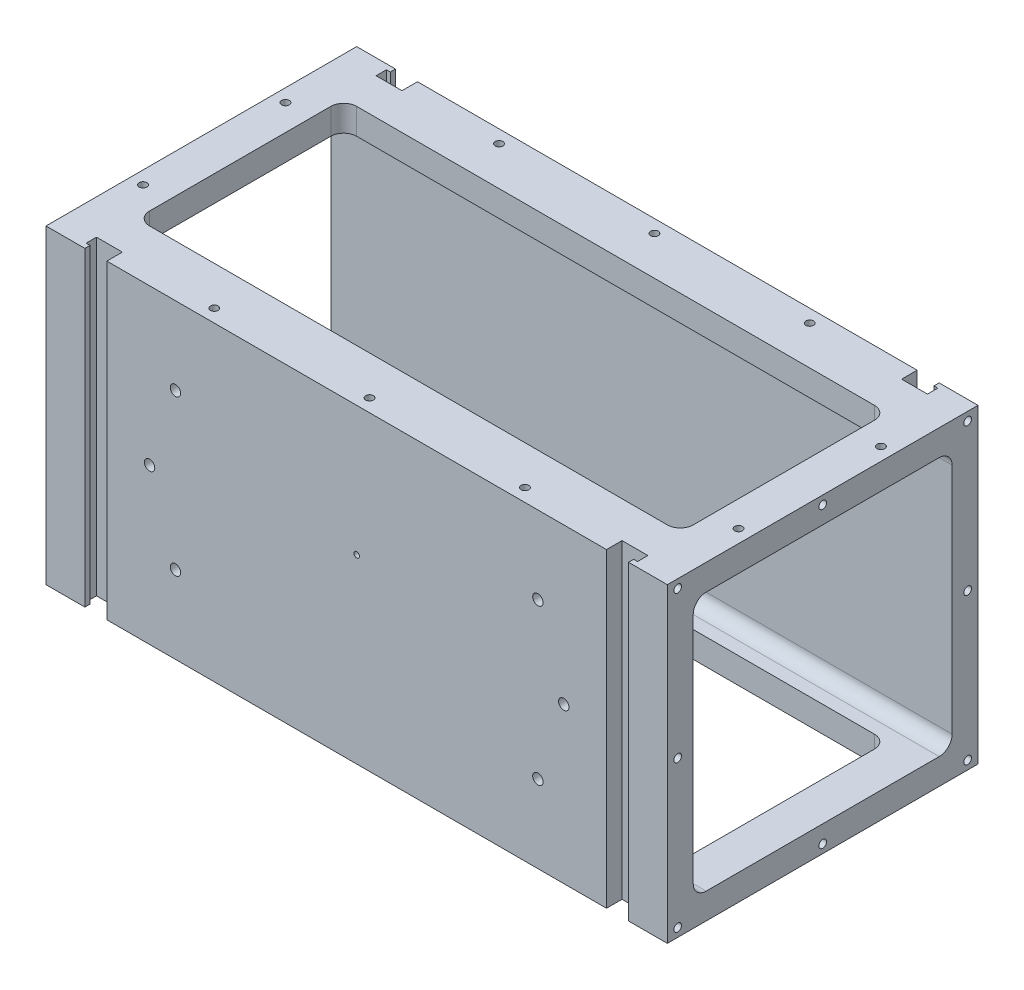
from build123d import *

# Parameters (mm, degrees)
SKETCH1_W                       = 304.8
SKETCH1_H                       = 152.4
BOSS_EXTRUDE1_DEPTH             = 152.4
CUT_EXTRUDE1_DEPTH              = 153.4
SKETCH6_W                       = 127
SKETCH6_H                       = 127
CUT_EXTRUDE5_DEPTH              = 305.8
CUT_EXTRUDE6_REACH              = 154.4
SKETCH7_W                       = 266.7
SKETCH7_H                       = 88.9
SKETCH8_W                       = 266.7
SKETCH8_H                       = 101.6
CUT_EXTRUDE7_DEPTH              = 153.4
F_1_4_20_TAPPED_HOLE2_D         = 5.1054
F_1_4_20_TAPPED_HOLE2_DEPTH     = 8.89
F_1_4_20_TAPPED_HOLE2_TIP       = 1.533816902
F_6_32_TAPPED_HOLE1_D           = 2.7051
F_6_32_TAPPED_HOLE1_DEPTH       = 9.38784
F_6_32_TAPPED_HOLE1_TIP         = 0.81269403
F_1_4_20_TAPPED_HOLE1_D         = 5.1054
F_1_4_20_TAPPED_HOLE1_DEPTH     = 8.89
F_1_4_20_TAPPED_HOLE1_TIP       = 1.533816902
F_10_24_TAPPED_HOLE1_AT_2_COUNT = 2
F_10_24_TAPPED_HOLE1_AT_2_PITCH = 78.094674114
F_10_24_TAPPED_HOLE1_AT_3_COUNT = 2
F_10_24_TAPPED_HOLE1_AT_3_PITCH = 292.1
F_10_24_TAPPED_HOLE1_AT_4_COUNT = 2
F_10_24_TAPPED_HOLE1_AT_4_PITCH = 224.977372473
F_10_24_TAPPED_HOLE1_AT_5_COUNT = 2
F_10_24_TAPPED_HOLE1_AT_5_PITCH = 300.335533196
F_10_24_TAPPED_HOLE1_AT_6_COUNT = 2
F_10_24_TAPPED_HOLE1_AT_6_PITCH = 245.708899157
F_10_24_TAPPED_HOLE1_AT_7_COUNT = 2
F_10_24_TAPPED_HOLE1_AT_7_PITCH = 69.85
F_10_24_TAPPED_HOLE1_AT_8_COUNT = 2
F_10_24_TAPPED_HOLE1_AT_8_PITCH = 125.923878296
F_10_24_TAPPED_HOLE2_AT_2_COUNT = 2
F_10_24_TAPPED_HOLE2_AT_2_PITCH = 139.7
F_10_24_TAPPED_HOLE5_AT_2_COUNT = 2
F_10_24_TAPPED_HOLE5_AT_2_PITCH = 144.018
F_10_24_TAPPED_HOLE5_AT_3_COUNT = 2
F_10_24_TAPPED_HOLE5_AT_3_PITCH = 202.41887739
F_10_24_TAPPED_HOLE5_AT_4_COUNT = 2
F_10_24_TAPPED_HOLE5_AT_4_PITCH = 160.621414276
F_10_24_TAPPED_HOLE5_AT_5_COUNT = 2
F_10_24_TAPPED_HOLE5_AT_5_PITCH = 142.24
F_10_24_TAPPED_HOLE5_AT_6_COUNT = 2
F_10_24_TAPPED_HOLE5_AT_6_PITCH = 159.428710341
F_10_24_TAPPED_HOLE5_AT_7_COUNT = 2
F_10_24_TAPPED_HOLE5_AT_7_PITCH = 71.086625417
F_10_24_TAPPED_HOLE5_AT_8_COUNT = 2
F_10_24_TAPPED_HOLE5_AT_8_PITCH = 72.009
F_6_32_TAPPED_HOLE2_D           = 2.7051
F_6_32_TAPPED_HOLE2_DEPTH       = 9.38784
F_6_32_TAPPED_HOLE2_TIP         = 0.81269403
FILLET1_R                       = 6.35
FILLET2_R                       = 6.35
MIRROR2_COPY_1_DEPTH            = 153.4
F_1_4_20_TAPPED_HOLE3_D         = 5.1054
F_1_4_20_TAPPED_HOLE3_DEPTH     = 7.8105
F_1_4_20_TAPPED_HOLE3_TIP       = 1.533816902


with BuildPart() as part:
    # Sketch1 → Boss-Extrude1 (new body)
    with BuildSketch(Plane.XY.offset(76.2)):
        Rectangle(SKETCH1_W, SKETCH1_H)
    extrude(amount=-BOSS_EXTRUDE1_DEPTH)

    # Sketch2 → Cut-Extrude1 (cut, through all)
    with BuildSketch(Plane(origin=(0, 76.2, 0), x_dir=(-1, 0, 0), z_dir=(0, 1, 0))):
        Polygon((133.35, -76.2), (133.35, -73.66), (135.255, -73.66), (135.255, -68.58), (122.555, -68.58), (122.555, -76.2), align=None)
    cut_extrude1 = extrude(amount=-CUT_EXTRUDE1_DEPTH, mode=Mode.SUBTRACT)

    # Sketch6 → Cut-Extrude5 (cut, through all)
    with BuildSketch(Plane.ZY.offset(152.4)):
        Rectangle(SKETCH6_W, SKETCH6_H)
    extrude(amount=-CUT_EXTRUDE5_DEPTH, mode=Mode.SUBTRACT)

    # Sketch7 → Cut-Extrude6 (cut, up to next)
    with BuildSketch(Plane.XZ.offset(76.2), mode=Mode.PRIVATE) as cut_extrude6_sk1:
        Rectangle(SKETCH7_W, SKETCH7_H)
    cut_extrude6_tool1 = extrude(cut_extrude6_sk1.sketch, amount=-CUT_EXTRUDE6_REACH, mode=Mode.PRIVATE) & part.part
    add(cut_extrude6_tool1.solids().sort_by_distance((0, -76.2, 0))[0], mode=Mode.SUBTRACT)

    # Sketch8 → Cut-Extrude7 (cut, through all)
    with BuildSketch(Plane(origin=(0, 76.2, 0), x_dir=(-1, 0, 0), z_dir=(0, 1, 0))):
        Rectangle(SKETCH8_W, SKETCH8_H)
    extrude(amount=-CUT_EXTRUDE7_DEPTH, mode=Mode.SUBTRACT)

    # 1/4-20 Tapped Hole2
    with Locations(Plane(origin=(0, 0, -76.2), x_dir=(-1, 0, 0), z_dir=(0, 0, -1))):
        with Locations((88.9, 38.1), (-88.9, 38.1), (88.9, -38.1), (-88.9, -38.1)):
            Hole(F_1_4_20_TAPPED_HOLE2_D / 2, depth=F_1_4_20_TAPPED_HOLE2_DEPTH)
            with Locations((0, 0, -(F_1_4_20_TAPPED_HOLE2_DEPTH + F_1_4_20_TAPPED_HOLE2_TIP / 2))):  # 118° drill point
                Cone(0, F_1_4_20_TAPPED_HOLE2_D / 2, F_1_4_20_TAPPED_HOLE2_TIP, mode=Mode.SUBTRACT)

    # #6-32 Tapped Hole1
    with Locations(Plane(origin=(0, 0, -76.2), x_dir=(-1, 0, 0), z_dir=(0, 0, -1))):
        with Locations((0, 12.7)):
            Hole(F_6_32_TAPPED_HOLE1_D / 2, depth=F_6_32_TAPPED_HOLE1_DEPTH)
            with Locations((0, 0, -(F_6_32_TAPPED_HOLE1_DEPTH + F_6_32_TAPPED_HOLE1_TIP / 2))):  # 118° drill point
                Cone(0, F_6_32_TAPPED_HOLE1_D / 2, F_6_32_TAPPED_HOLE1_TIP, mode=Mode.SUBTRACT)

    # 1/4-20 Tapped Hole1
    with Locations(Plane.XY.offset(76.2)):
        with Locations((-88.9, -38.1), (88.9, -38.1), (88.9, 38.1), (-88.9, 38.1)):
            Hole(F_1_4_20_TAPPED_HOLE1_D / 2, depth=F_1_4_20_TAPPED_HOLE1_DEPTH)
            with Locations((0, 0, -(F_1_4_20_TAPPED_HOLE1_DEPTH + F_1_4_20_TAPPED_HOLE1_TIP / 2))):  # 118° drill point
                Cone(0, F_1_4_20_TAPPED_HOLE1_D / 2, F_1_4_20_TAPPED_HOLE1_TIP, mode=Mode.SUBTRACT)

    # Sketch15 → #10-24 Tapped Hole1 (revolve, cut)
    with BuildSketch(Plane(origin=(-146.05, 76.2, 34.925), x_dir=(0, 0, 1), z_dir=(1, 0, 0))):
        Polygon((0, 0), (0, 8.890364014), (1.89865, 7.74954), (1.89865, 0), align=None)
    f_10_24_tapped_hole1 = revolve(axis=Axis((-146.05, 82.55, 34.925), (0, -1, 0)), mode=Mode.SUBTRACT)

    # #10-24 Tapped Hole1 at 2: #10-24 Tapped Hole1 ×2
    with Locations(*[Vector(0.894427191, 0, 0.447213595) * (i * F_10_24_TAPPED_HOLE1_AT_2_PITCH) for i in range(1, F_10_24_TAPPED_HOLE1_AT_2_COUNT)]):
        add(f_10_24_tapped_hole1, mode=Mode.SUBTRACT)

    # #10-24 Tapped Hole1 at 3: #10-24 Tapped Hole1 ×2
    with Locations(*[(i * F_10_24_TAPPED_HOLE1_AT_3_PITCH, 0, 0) for i in range(1, F_10_24_TAPPED_HOLE1_AT_3_COUNT)]):
        add(f_10_24_tapped_hole1, mode=Mode.SUBTRACT)

    # #10-24 Tapped Hole1 at 4: #10-24 Tapped Hole1 ×2
    with Locations(*[Vector(0.987877125, 0, 0.155237834) * (i * F_10_24_TAPPED_HOLE1_AT_4_PITCH) for i in range(1, F_10_24_TAPPED_HOLE1_AT_4_COUNT)]):
        add(f_10_24_tapped_hole1, mode=Mode.SUBTRACT)

    # #10-24 Tapped Hole1 at 5: #10-24 Tapped Hole1 ×2
    with Locations(*[Vector(0.972578892, 0, -0.232573213) * (i * F_10_24_TAPPED_HOLE1_AT_5_PITCH) for i in range(1, F_10_24_TAPPED_HOLE1_AT_5_COUNT)]):
        add(f_10_24_tapped_hole1, mode=Mode.SUBTRACT)

    # #10-24 Tapped Hole1 at 6: #10-24 Tapped Hole1 ×2
    with Locations(*[Vector(0.904525643, 0, -0.426419232) * (i * F_10_24_TAPPED_HOLE1_AT_6_PITCH) for i in range(1, F_10_24_TAPPED_HOLE1_AT_6_COUNT)]):
        add(f_10_24_tapped_hole1, mode=Mode.SUBTRACT)

    # #10-24 Tapped Hole1 at 7: #10-24 Tapped Hole1 ×2
    with Locations(*[(0, 0, -i * F_10_24_TAPPED_HOLE1_AT_7_PITCH) for i in range(1, F_10_24_TAPPED_HOLE1_AT_7_COUNT)]):
        add(f_10_24_tapped_hole1, mode=Mode.SUBTRACT)

    # #10-24 Tapped Hole1 at 8: #10-24 Tapped Hole1 ×2
    with Locations(*[Vector(0.554700196, 0, -0.832050294) * (i * F_10_24_TAPPED_HOLE1_AT_8_PITCH) for i in range(1, F_10_24_TAPPED_HOLE1_AT_8_COUNT)]):
        add(f_10_24_tapped_hole1, mode=Mode.SUBTRACT)

    # Sketch17 → #10-24 Tapped Hole2 (revolve, cut)
    with BuildSketch(Plane(origin=(0, 76.2, 69.85), x_dir=(0, 0, 1), z_dir=(1, 0, 0))):
        Polygon((0, 0), (0, 13.970364014), (1.89865, 12.82954), (1.89865, 0), align=None)
    f_10_24_tapped_hole2 = revolve(axis=Axis((0, 82.55, 69.85), (0, -1, 0)), mode=Mode.SUBTRACT)

    # #10-24 Tapped Hole2 at 2: #10-24 Tapped Hole2 ×2
    with Locations(*[(0, 0, -i * F_10_24_TAPPED_HOLE2_AT_2_PITCH) for i in range(1, F_10_24_TAPPED_HOLE2_AT_2_COUNT)]):
        add(f_10_24_tapped_hole2, mode=Mode.SUBTRACT)

    # Sketch25 → #10-24 Tapped Hole5 (revolve, cut)
    with BuildSketch(Plane(origin=(152.4, 72.009, -71.12), x_dir=(0, 0, -1), z_dir=(0, 1, 0))):
        Polygon((0, 0), (0, 11.430364014), (1.89865, 10.28954), (1.89865, 0), align=None)
    f_10_24_tapped_hole5 = revolve(axis=Axis((158.75, 72.009, -71.12), (-1, 0, 0)), mode=Mode.SUBTRACT)

    # #10-24 Tapped Hole5 at 2: #10-24 Tapped Hole5 ×2
    with Locations(*[(0, -i * F_10_24_TAPPED_HOLE5_AT_2_PITCH, 0) for i in range(1, F_10_24_TAPPED_HOLE5_AT_2_COUNT)]):
        add(f_10_24_tapped_hole5, mode=Mode.SUBTRACT)

    # #10-24 Tapped Hole5 at 3: #10-24 Tapped Hole5 ×2
    with Locations(*[Vector(0, -0.711485025, 0.702701259) * (i * F_10_24_TAPPED_HOLE5_AT_3_PITCH) for i in range(1, F_10_24_TAPPED_HOLE5_AT_3_COUNT)]):
        add(f_10_24_tapped_hole5, mode=Mode.SUBTRACT)

    # #10-24 Tapped Hole5 at 4: #10-24 Tapped Hole5 ×2
    with Locations(*[Vector(0, -0.896630133, 0.442780312) * (i * F_10_24_TAPPED_HOLE5_AT_4_PITCH) for i in range(1, F_10_24_TAPPED_HOLE5_AT_4_COUNT)]):
        add(f_10_24_tapped_hole5, mode=Mode.SUBTRACT)

    # #10-24 Tapped Hole5 at 5: #10-24 Tapped Hole5 ×2
    with Locations(*[(0, 0, i * F_10_24_TAPPED_HOLE5_AT_5_PITCH) for i in range(1, F_10_24_TAPPED_HOLE5_AT_5_COUNT)]):
        add(f_10_24_tapped_hole5, mode=Mode.SUBTRACT)

    # #10-24 Tapped Hole5 at 6: #10-24 Tapped Hole5 ×2
    with Locations(*[Vector(0, -0.451668961, 0.892185603) * (i * F_10_24_TAPPED_HOLE5_AT_6_PITCH) for i in range(1, F_10_24_TAPPED_HOLE5_AT_6_COUNT)]):
        add(f_10_24_tapped_hole5, mode=Mode.SUBTRACT)

    # #10-24 Tapped Hole5 at 7: #10-24 Tapped Hole5 ×2
    with Locations(*[(0, 0, i * F_10_24_TAPPED_HOLE5_AT_7_PITCH) for i in range(1, F_10_24_TAPPED_HOLE5_AT_7_COUNT)]):
        add(f_10_24_tapped_hole5, mode=Mode.SUBTRACT)

    # #10-24 Tapped Hole5 at 8: #10-24 Tapped Hole5 ×2
    with Locations(*[(0, -i * F_10_24_TAPPED_HOLE5_AT_8_PITCH, 0) for i in range(1, F_10_24_TAPPED_HOLE5_AT_8_COUNT)]):
        add(f_10_24_tapped_hole5, mode=Mode.SUBTRACT)

    # #6-32 Tapped Hole2
    with Locations(Plane.XY.offset(76.2)):
        with Locations((0, 12.7)):
            Hole(F_6_32_TAPPED_HOLE2_D / 2, depth=F_6_32_TAPPED_HOLE2_DEPTH)
            with Locations((0, 0, -(F_6_32_TAPPED_HOLE2_DEPTH + F_6_32_TAPPED_HOLE2_TIP / 2))):  # 118° drill point
                Cone(0, F_6_32_TAPPED_HOLE2_D / 2, F_6_32_TAPPED_HOLE2_TIP, mode=Mode.SUBTRACT)

    # Fillet1
    fillet1_edges = [part.edges().sort_by_distance(p)[0] for p in [
        (133.35, -69.85, 50.8),
        (133.35, 69.85, 50.8),
        (-133.35, -69.85, -50.8),
        (-133.35, 69.85, -50.8),
        (-133.35, -69.85, 50.8),
        (-133.35, 69.85, 50.8),
        (133.35, -69.85, -50.8),
        (133.35, 69.85, -50.8),
    ]]
    fillet(fillet1_edges, radius=FILLET1_R)

    # Fillet2
    fillet2_edges = [part.edges().sort_by_distance(p)[0] for p in [
        (0, 63.5, 63.5),
        (0, -63.5, 63.5),
        (0, -63.5, -63.5),
        (0, 63.5, -63.5),
    ]]
    fillet(fillet2_edges, radius=FILLET2_R)

    # Mirror1: Cut-Extrude1 across plane
    add(cut_extrude1.mirror(Plane(origin=(0, 0, 0), x_dir=(0, 0, 1), z_dir=(1, 0, 0))), mode=Mode.SUBTRACT)

    # Mirror2: Cut-Extrude1 across plane
    add(cut_extrude1.mirror(Plane.XY), mode=Mode.SUBTRACT)

    # Mirror2 copy 1 sketch → Mirror2 copy 1 (cut, through all)
    with BuildSketch(Plane(origin=(0, 76.2, 0), x_dir=(1, 0, 0), z_dir=(0, 1, 0))):
        Polygon((133.35, -76.2), (133.35, -73.66), (135.255, -73.66), (135.255, -68.58), (122.555, -68.58), (122.555, -76.2), align=None)
    extrude(amount=-MIRROR2_COPY_1_DEPTH, mode=Mode.SUBTRACT)

    # Mirror3: #10-24 Tapped Hole2, #10-24 Tapped Hole1 across plane
    add(f_10_24_tapped_hole2.mirror(Plane.ZX), mode=Mode.SUBTRACT)
    add(f_10_24_tapped_hole1.mirror(Plane.ZX), mode=Mode.SUBTRACT)

    # Mirror3 copy 1 sketch → Mirror3 copy 1 (revolve, cut)
    with BuildSketch(Plane(origin=(0, -76.2, -69.85), x_dir=(0, 0, 1), z_dir=(1, 0, 0))):
        Polygon((0, 0), (0, -13.970364014), (1.89865, -12.82954), (1.89865, 0), align=None)
    revolve(axis=Axis((0, -82.55, -69.85), (0, -1, 0)), mode=Mode.SUBTRACT)

    # Mirror3 copy 2 sketch → Mirror3 copy 2 (revolve, cut)
    with BuildSketch(Plane(origin=(-76.2, -76.2, 69.85), x_dir=(0, 0, 1), z_dir=(1, 0, 0))):
        Polygon((0, 0), (0, -8.890364014), (1.89865, -7.74954), (1.89865, 0), align=None)
    revolve(axis=Axis((-76.2, -82.55, 69.85), (0, -1, 0)), mode=Mode.SUBTRACT)

    # Mirror3 copy 3 sketch → Mirror3 copy 3 (revolve, cut)
    with BuildSketch(Plane(origin=(146.05, -76.2, 34.925), x_dir=(0, 0, 1), z_dir=(1, 0, 0))):
        Polygon((0, 0), (0, -8.890364014), (1.89865, -7.74954), (1.89865, 0), align=None)
    revolve(axis=Axis((146.05, -82.55, 34.925), (0, -1, 0)), mode=Mode.SUBTRACT)

    # Mirror3 copy 4 sketch → Mirror3 copy 4 (revolve, cut)
    with BuildSketch(Plane(origin=(76.2, -76.2, 69.85), x_dir=(0, 0, 1), z_dir=(1, 0, 0))):
        Polygon((0, 0), (0, -8.890364014), (1.89865, -7.74954), (1.89865, 0), align=None)
    revolve(axis=Axis((76.2, -82.55, 69.85), (0, -1, 0)), mode=Mode.SUBTRACT)

    # Mirror3 copy 5 sketch → Mirror3 copy 5 (revolve, cut)
    with BuildSketch(Plane(origin=(146.05, -76.2, -34.925), x_dir=(0, 0, 1), z_dir=(1, 0, 0))):
        Polygon((0, 0), (0, -8.890364014), (1.89865, -7.74954), (1.89865, 0), align=None)
    revolve(axis=Axis((146.05, -82.55, -34.925), (0, -1, 0)), mode=Mode.SUBTRACT)

    # Mirror3 copy 6 sketch → Mirror3 copy 6 (revolve, cut)
    with BuildSketch(Plane(origin=(76.2, -76.2, -69.85), x_dir=(0, 0, 1), z_dir=(1, 0, 0))):
        Polygon((0, 0), (0, -8.890364014), (1.89865, -7.74954), (1.89865, 0), align=None)
    revolve(axis=Axis((76.2, -82.55, -69.85), (0, -1, 0)), mode=Mode.SUBTRACT)

    # Mirror3 copy 7 sketch → Mirror3 copy 7 (revolve, cut)
    with BuildSketch(Plane(origin=(-146.05, -76.2, -34.925), x_dir=(0, 0, 1), z_dir=(1, 0, 0))):
        Polygon((0, 0), (0, -8.890364014), (1.89865, -7.74954), (1.89865, 0), align=None)
    revolve(axis=Axis((-146.05, -82.55, -34.925), (0, -1, 0)), mode=Mode.SUBTRACT)

    # Mirror3 copy 8 sketch → Mirror3 copy 8 (revolve, cut)
    with BuildSketch(Plane(origin=(-76.2, -76.2, -69.85), x_dir=(0, 0, 1), z_dir=(1, 0, 0))):
        Polygon((0, 0), (0, -8.890364014), (1.89865, -7.74954), (1.89865, 0), align=None)
    revolve(axis=Axis((-76.2, -82.55, -69.85), (0, -1, 0)), mode=Mode.SUBTRACT)

    # Mirror4: #10-24 Tapped Hole5 across plane
    add(f_10_24_tapped_hole5.mirror(Plane(origin=(0, 0, 0), x_dir=(0, 0, 1), z_dir=(1, 0, 0))), mode=Mode.SUBTRACT)

    # Mirror4 copy 1 sketch → Mirror4 copy 1 (revolve, cut)
    with BuildSketch(Plane(origin=(-152.4, -72.009, -71.12), x_dir=(0, 0, -1), z_dir=(0, 1, 0))):
        Polygon((0, 0), (0, -11.430364014), (1.89865, -10.28954), (1.89865, 0), align=None)
    revolve(axis=Axis((-158.75, -72.009, -71.12), (-1, 0, 0)), mode=Mode.SUBTRACT)

    # Mirror4 copy 2 sketch → Mirror4 copy 2 (revolve, cut)
    with BuildSketch(Plane(origin=(-152.4, -72.009, 71.12), x_dir=(0, 0, -1), z_dir=(0, 1, 0))):
        Polygon((0, 0), (0, -11.430364014), (1.89865, -10.28954), (1.89865, 0), align=None)
    revolve(axis=Axis((-158.75, -72.009, 71.12), (-1, 0, 0)), mode=Mode.SUBTRACT)

    # Mirror4 copy 3 sketch → Mirror4 copy 3 (revolve, cut)
    with BuildSketch(Plane(origin=(-152.4, -72.009, 0), x_dir=(0, 0, -1), z_dir=(0, 1, 0))):
        Polygon((0, 0), (0, -11.430364014), (1.89865, -10.28954), (1.89865, 0), align=None)
    revolve(axis=Axis((-158.75, -72.009, 0), (-1, 0, 0)), mode=Mode.SUBTRACT)

    # Mirror4 copy 4 sketch → Mirror4 copy 4 (revolve, cut)
    with BuildSketch(Plane(origin=(-152.4, 72.009, 71.12), x_dir=(0, 0, -1), z_dir=(0, 1, 0))):
        Polygon((0, 0), (0, -11.430364014), (1.89865, -10.28954), (1.89865, 0), align=None)
    revolve(axis=Axis((-158.75, 72.009, 71.12), (-1, 0, 0)), mode=Mode.SUBTRACT)

    # Mirror4 copy 5 sketch → Mirror4 copy 5 (revolve, cut)
    with BuildSketch(Plane(origin=(-152.4, 0, 71.12), x_dir=(0, 0, -1), z_dir=(0, 1, 0))):
        Polygon((0, 0), (0, -11.430364014), (1.89865, -10.28954), (1.89865, 0), align=None)
    revolve(axis=Axis((-158.75, 0, 71.12), (-1, 0, 0)), mode=Mode.SUBTRACT)

    # Mirror4 copy 6 sketch → Mirror4 copy 6 (revolve, cut)
    with BuildSketch(Plane(origin=(-152.4, 72.009, -0.033374583), x_dir=(0, 0, -1), z_dir=(0, 1, 0))):
        Polygon((0, 0), (0, -11.430364014), (1.89865, -10.28954), (1.89865, 0), align=None)
    revolve(axis=Axis((-158.75, 72.009, -0.033374583), (-1, 0, 0)), mode=Mode.SUBTRACT)

    # Mirror4 copy 7 sketch → Mirror4 copy 7 (revolve, cut)
    with BuildSketch(Plane(origin=(-152.4, 0, -71.12), x_dir=(0, 0, -1), z_dir=(0, 1, 0))):
        Polygon((0, 0), (0, -11.430364014), (1.89865, -10.28954), (1.89865, 0), align=None)
    revolve(axis=Axis((-158.75, 0, -71.12), (-1, 0, 0)), mode=Mode.SUBTRACT)

    # 1/4-20 Tapped Hole3
    with Locations(Plane.XY.offset(76.2)):
        with Locations((-101.6, 0), (101.6, 0)):
            Hole(F_1_4_20_TAPPED_HOLE3_D / 2, depth=F_1_4_20_TAPPED_HOLE3_DEPTH)
            with Locations((0, 0, -(F_1_4_20_TAPPED_HOLE3_DEPTH + F_1_4_20_TAPPED_HOLE3_TIP / 2))):  # 118° drill point
                Cone(0, F_1_4_20_TAPPED_HOLE3_D / 2, F_1_4_20_TAPPED_HOLE3_TIP, mode=Mode.SUBTRACT)


solid = part.part
